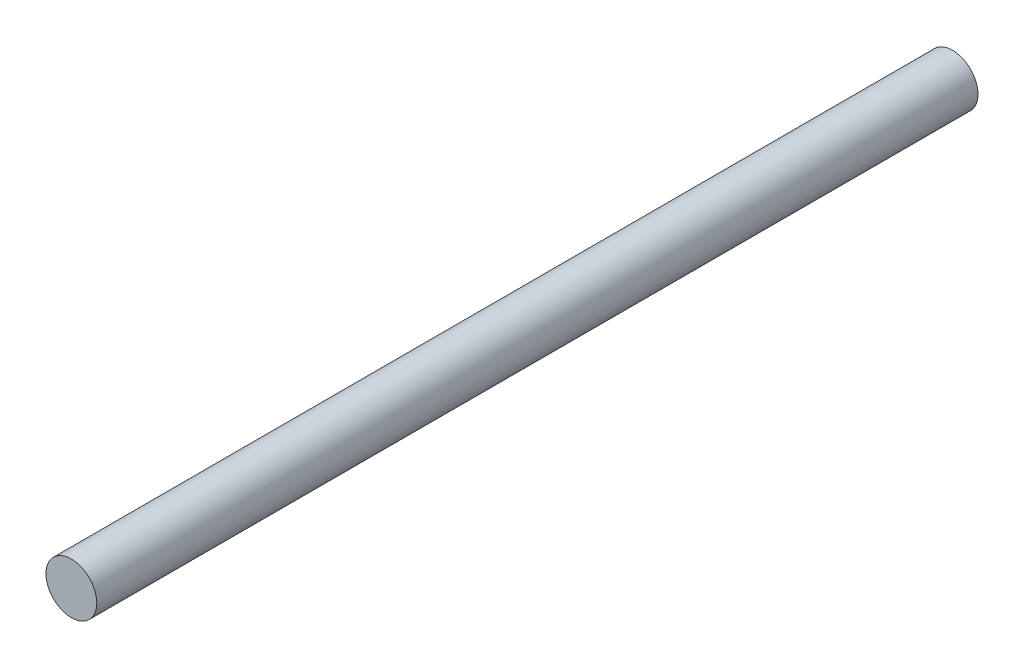
from build123d import *

# Parameters (mm, degrees)
SKETCH1_R           = 19.05
BOSS_EXTRUDE1_DEPTH = 330.2


with BuildPart() as part:
    # Sketch1 → Boss-Extrude1 (new body, symmetric)
    with BuildSketch(Plane.XY):
        Circle(SKETCH1_R)
    extrude(amount=BOSS_EXTRUDE1_DEPTH, both=True)


solid = part.part
